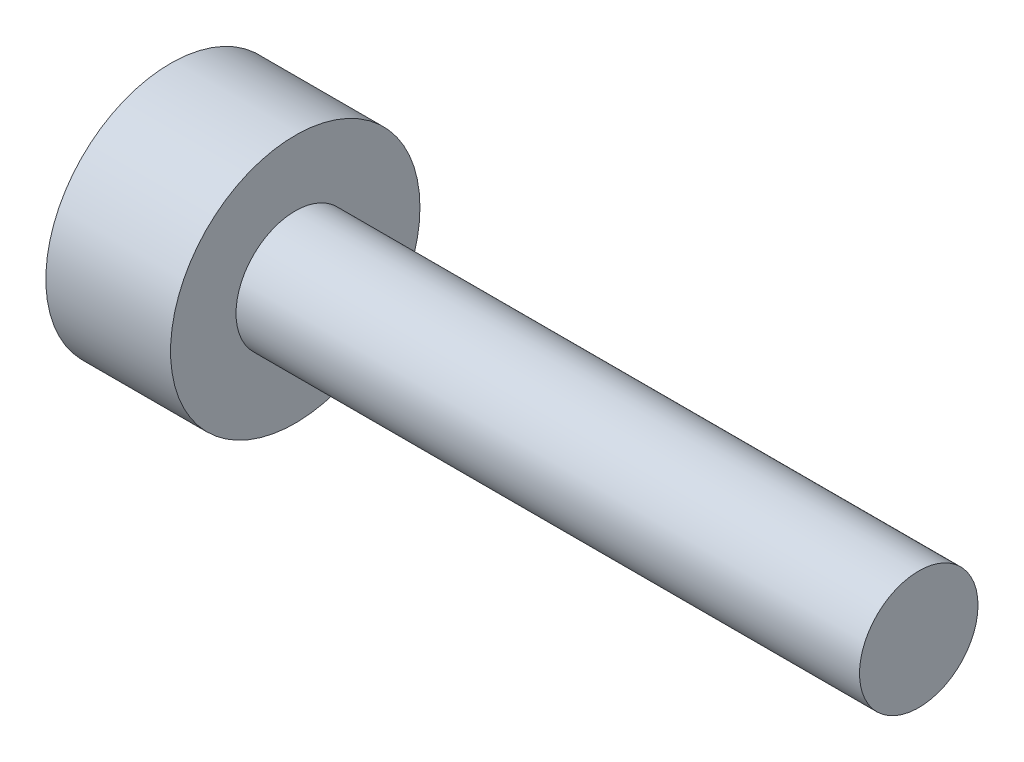
from build123d import *

# Parameters (mm, degrees)
SKETCH1_R           = 10
BOSS_EXTRUDE1_DEPTH = 10
SKETCH2_R           = 4.75
BOSS_EXTRUDE2_DEPTH = 50


with BuildPart() as part:
    # Sketch1 → Boss-Extrude1 (new body)
    with BuildSketch(Plane(origin=(0, 0, 0), x_dir=(0, 0, -1), z_dir=(1, 0, 0))):
        Circle(SKETCH1_R)
    extrude(amount=BOSS_EXTRUDE1_DEPTH)

    # Sketch2 → Boss-Extrude2 (add)
    with BuildSketch(Plane(origin=(10, 0, 0), x_dir=(0, 0, -1), z_dir=(1, 0, 0))):
        Circle(SKETCH2_R)
    extrude(amount=BOSS_EXTRUDE2_DEPTH)


solid = part.part
